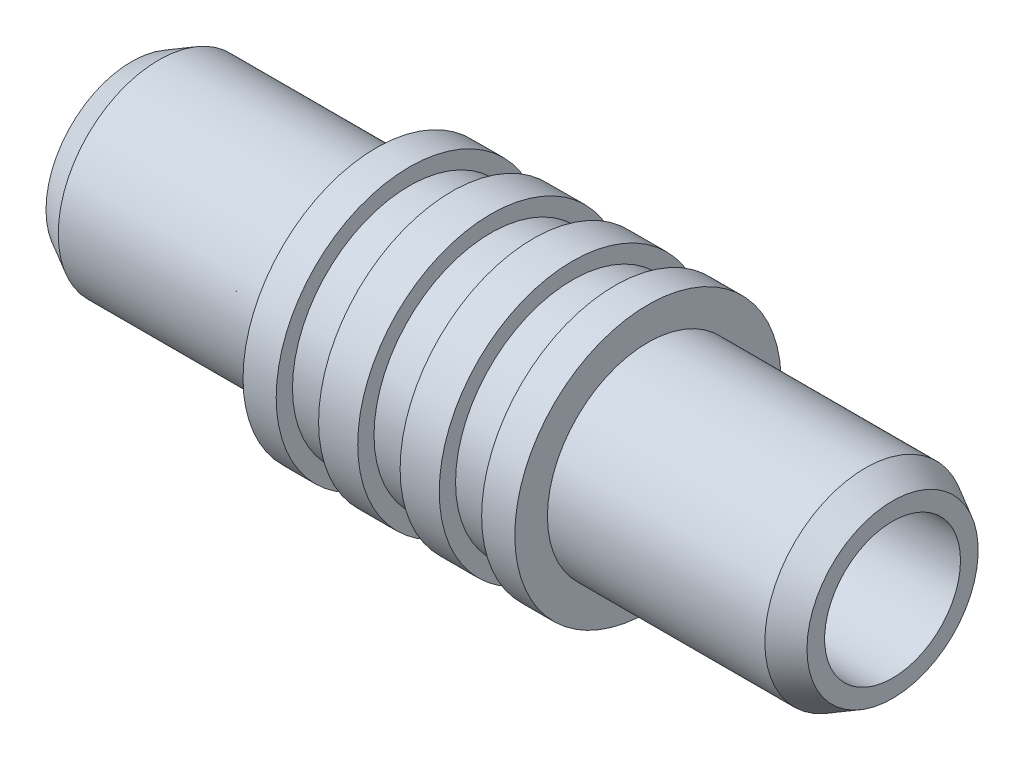
from build123d import *

# Parameters (mm, degrees)
SKETCH2_W          = 1.9812
SKETCH2_H          = 1.524
SKETCH3_R          = 3.175
CUT_EXTRUDE1_DEPTH = 6.2992


with BuildPart() as part:
    # Sketch1 → Revolve1 (revolve)
    with BuildSketch(Plane.XY):
        Polygon((0, 2.0193), (17.78, 2.0193), (17.78, 4.0005), (16.51, 4.699), (6.35, 4.699), (6.35, 6.223), (0, 6.223), align=None)
    revolve1 = revolve(axis=Axis((0, 0, 0), (1, 0, 0)))

    # Mirror1: Revolve1 across plane
    add(revolve1.mirror(Plane(origin=(0, 6.223, 0), x_dir=(0, 0, 1), z_dir=(1, 0, 0))))

    # Sketch2 → Cut-Revolve1 (revolve, cut)
    with BuildSketch(Plane.XY):
        with Locations((0, 6.223)):
            Rectangle(SKETCH2_W, SKETCH2_H)
        with Locations((-3.81, 6.223)):
            Rectangle(SKETCH2_W, SKETCH2_H)
        with Locations((3.81, 6.223)):
            Rectangle(SKETCH2_W, SKETCH2_H)
    revolve(axis=Axis((0, 0, 0), (1, 0, 0)), mode=Mode.SUBTRACT)

    # Sketch3 → Cut-Extrude1 (cut)
    with BuildSketch(Plane(origin=(17.78, 0, 0), x_dir=(0, 0, -1), z_dir=(1, 0, 0))):
        Circle(SKETCH3_R)
    extrude(amount=-CUT_EXTRUDE1_DEPTH, mode=Mode.SUBTRACT)


solid = part.part
